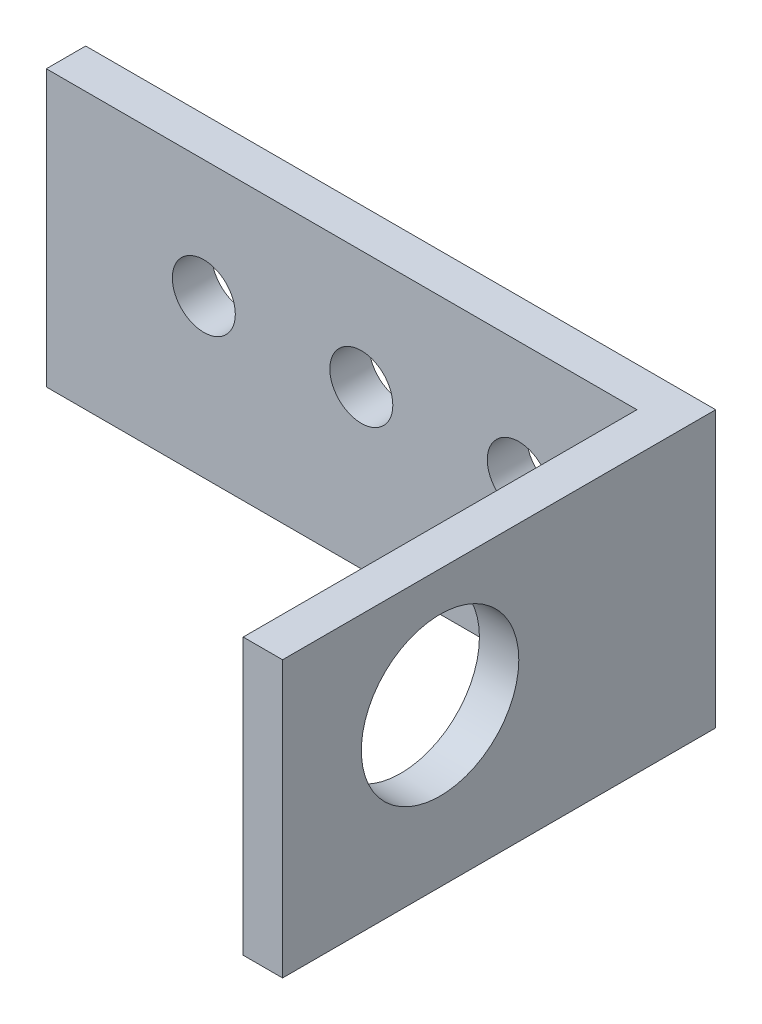
from build123d import *

# Parameters (mm, degrees)
BOSS_EXTRUDE1_DEPTH = 22.225
SKETCH2_R           = 6.35
CUT_EXTRUDE1_DEPTH  = 3.175
SKETCH3_R           = 2.54
CUT_EXTRUDE2_DEPTH  = 3.175


with BuildPart() as part:
    # Sketch1 → Boss-Extrude1 (new body)
    with BuildSketch(Plane(origin=(0, 0, 0), x_dir=(1, 0, 0), z_dir=(0, 1, 0))):
        Polygon((22.225, 14.2875), (22.225, -17.4625), (25.4, -17.4625), (25.4, 17.4625), (-25.4, 17.4625), (-25.4, 14.2875), align=None)
    extrude(amount=BOSS_EXTRUDE1_DEPTH)

    # Sketch2 → Cut-Extrude1 (cut)
    with BuildSketch(Plane(origin=(25.4, 0, 0), x_dir=(0, 0, -1), z_dir=(1, 0, 0))):
        with Locations((-4.7625, 12.7)):
            Circle(SKETCH2_R)
    extrude(amount=-CUT_EXTRUDE1_DEPTH, mode=Mode.SUBTRACT)

    # Sketch3 → Cut-Extrude2 (cut)
    with BuildSketch(Plane.XY.offset(-14.2875)):
        with Locations((-12.7, 12.7)):
            Circle(SKETCH3_R)
        with Locations((0, 12.7)):
            Circle(SKETCH3_R)
        with Locations((12.7, 12.7)):
            Circle(SKETCH3_R)
    extrude(amount=-CUT_EXTRUDE2_DEPTH, mode=Mode.SUBTRACT)


solid = part.part
